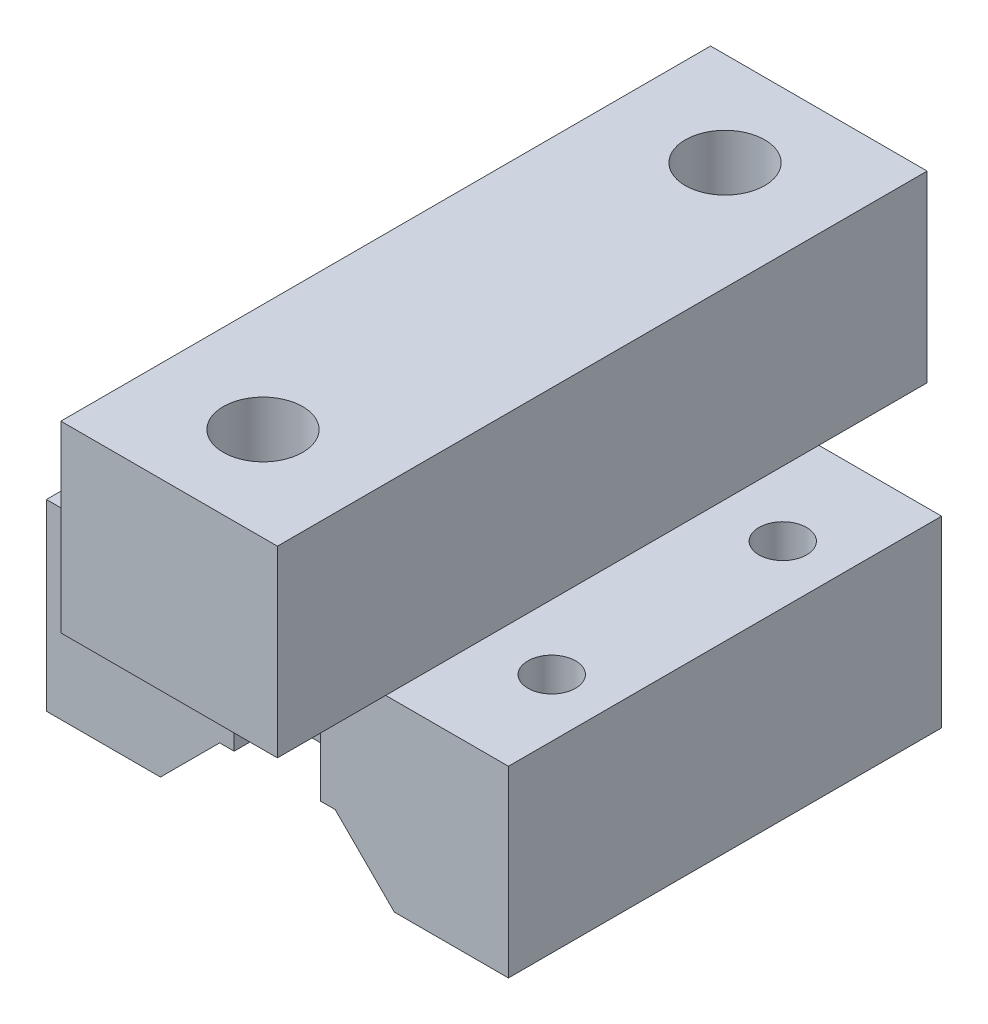
from build123d import *

# Parameters (mm, degrees)
BOSS_EXTRUDE1_DEPTH = 15
SKETCH2_R           = 1.65
CUT_EXTRUDE1_DEPTH  = 12.7
SKETCH3_W           = 4.5
SKETCH3_H           = 7.5
BOSS_EXTRUDE3_DEPTH = 12.7
SKETCH3_7_W         = 6
SKETCH3_7_H         = 3.5
CUT_EXTRUDE4_DEPTH  = 12.7


with BuildPart() as part:
    # Sketch1 → Boss-Extrude1 (new body, symmetric)
    with BuildSketch(Plane.XY):
        Polygon((-4, 4.101219331), (4, 4.101219331), (8.101219331, 0), (16, 0), (16, 12.7), (-16, 12.7), (-16, 0), (-8.101219331, 0), align=None)
    extrude(amount=BOSS_EXTRUDE1_DEPTH, both=True)

    # Sketch2 → Cut-Extrude1 (cut)
    with BuildSketch(Plane(origin=(0, 12.7, 0), x_dir=(1, 0, 0), z_dir=(0, 1, 0))):
        with Locations((12, 8)):
            Circle(SKETCH2_R)
        with Locations((12, -8)):
            Circle(SKETCH2_R)
        with Locations((-12, -8)):
            Circle(SKETCH2_R)
        with Locations((-12, 8)):
            Circle(SKETCH2_R)
    extrude(amount=-CUT_EXTRUDE1_DEPTH, mode=Mode.SUBTRACT)

    # Sketch3 → Boss-Extrude3 (add)
    with BuildSketch(Plane(origin=(0, 12.7, 0), x_dir=(1, 0, 0), z_dir=(0, 1, 0))):
        with Locations((5.25, 18.75)):
            Rectangle(SKETCH3_W, SKETCH3_H)
        Polygon((3, -15), (7.5, -15), (7.5, 15), (3, 15), (3, 11.5), (-3, 11.5), (-3, 15), (-7.5, 15), (-7.5, -15), (-3, -15), (-3, -11.5), (3, -11.5), align=None)
        with Locations((-5.25, 18.75)):
            Rectangle(SKETCH3_W, SKETCH3_H)
        with BuildLine():
            Line((2.561737691, 15), (3, 15))
            Line((3, 15), (3, 22.5))
            Line((3, 22.5), (-3, 22.5))
            Line((-3, 22.5), (-3, 15))
            Line((-3, 15), (-2.561737691, 15))
            ThreePointArc((-2.561737691, 15), (-0.508783524, 18.702524621), (2.75, 16))
            ThreePointArc((2.75, 16), (2.702524621, 15.491216476), (2.561737691, 15))
        make_face()
        with BuildLine():
            Line((3, 11.5), (3, 15))
            Line((3, 15), (2.561737691, 15))
            ThreePointArc((2.561737691, 15), (0, 13.25), (-2.561737691, 15))
            Line((-2.561737691, 15), (-3, 15))
            Line((-3, 15), (-3, 11.5))
            Line((-3, 11.5), (3, 11.5))
        make_face()
        with BuildLine():
            Line((-3, -22.5), (3, -22.5))
            Line((3, -22.5), (3, -15))
            Line((3, -15), (2.561737691, -15))
            ThreePointArc((2.561737691, -15), (2.702524621, -15.491216476), (2.75, -16))
            ThreePointArc((2.75, -16), (-0.508783524, -18.702524621), (-2.561737691, -15))
            Line((-2.561737691, -15), (-3, -15))
            Line((-3, -15), (-3, -22.5))
        make_face()
        with Locations((5.25, -18.75)):
            Rectangle(SKETCH3_W, SKETCH3_H)
        with Locations((-5.25, -18.75)):
            Rectangle(SKETCH3_W, SKETCH3_H)
        with BuildLine():
            Line((2.561737691, -15), (3, -15))
            Line((3, -15), (3, -11.5))
            Line((3, -11.5), (-3, -11.5))
            Line((-3, -11.5), (-3, -15))
            Line((-3, -15), (-2.561737691, -15))
            ThreePointArc((-2.561737691, -15), (0, -13.25), (2.561737691, -15))
        make_face()
    extrude(amount=BOSS_EXTRUDE3_DEPTH)

    # Sketch3_7 → Cut-Extrude4 (cut)
    with BuildSketch(Plane(origin=(0, 12.7, 0), x_dir=(1, 0, 0), z_dir=(0, 1, 0))):
        with Locations((0, -13.25)):
            Rectangle(SKETCH3_7_W, SKETCH3_7_H)
        with Locations((0, 13.25)):
            Rectangle(SKETCH3_7_W, SKETCH3_7_H)
    extrude(amount=-CUT_EXTRUDE4_DEPTH, mode=Mode.SUBTRACT)


solid = part.part
